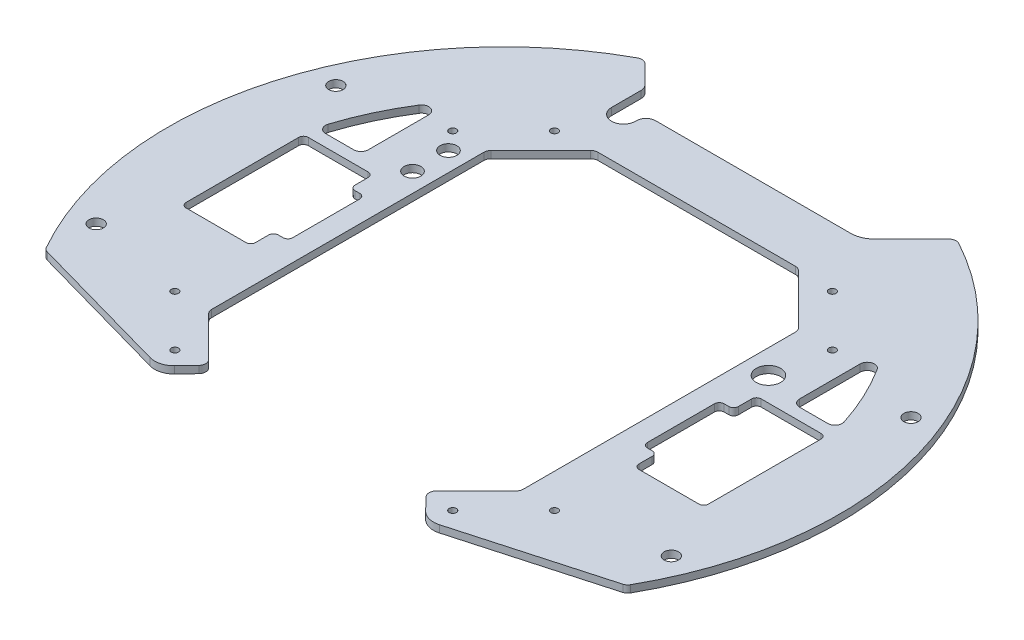
from build123d import *

# Parameters (mm, degrees)
SKETCH1_R            = 140
BOSS_EXTRUDE1_DEPTH  = 3
CUT_EXTRUDE1_REACH   = 5
CUT_EXTRUDE3_REACH   = 5
SKETCH19_R           = 1.5
CUT_EXTRUDE4_REACH   = 5
CUT_EXTRUDE5_REACH   = 5
FILLET1_R            = 20
FILLET2_R            = 10
CUT_EXTRUDE6_REACH   = 5
SKETCH22_W           = 29
SKETCH22_H           = 51
CUT_EXTRUDE15_REACH  = 5
SKETCH31_W           = 6
SKETCH31_H           = 32
FILLET3_R            = 2
CUT_EXTRUDE7_REACH   = 5
SKETCH23_R           = 3
CUT_EXTRUDE8_DEPTH   = 3
FILLET4_R            = 3
FILLET4_OF_MIRROR1_R = 3
CUT_EXTRUDE10_START  = -3
CUT_EXTRUDE10_DEPTH  = 3
CUT_EXTRUDE11_REACH  = 5
SKETCH27_W           = 84.933880008
SKETCH27_H           = 18.347014885
CUT_EXTRUDE12_REACH  = 5
FILLET5_R            = 3
FILLET6_R            = 4
CUT_EXTRUDE13_REACH  = 5
SKETCH29_R           = 5.1
CUT_EXTRUDE14_REACH  = 5
SKETCH30_R           = 3.5


with BuildPart() as part:
    # Sketch1 → Boss-Extrude1 (new body)
    with BuildSketch(Plane(origin=(0, 0, 0), x_dir=(1, 0, 0), z_dir=(0, 1, 0))):
        Circle(SKETCH1_R)
    extrude(amount=BOSS_EXTRUDE1_DEPTH)

    # Sketch17 → Cut-Extrude1 (cut, up to next)
    with BuildSketch(Plane.XZ, mode=Mode.PRIVATE) as cut_extrude1_sk1:
        Polygon((-50, 90), (-121.24355653, 70), (-121.24355653, 140), (121.24355653, 140), (121.24355653, 70), (50, 90), align=None)
    cut_extrude1_tool1 = extrude(cut_extrude1_sk1.sketch, amount=-CUT_EXTRUDE1_REACH, mode=Mode.PRIVATE) & part.part
    add(cut_extrude1_tool1.solids().sort_by_distance((0, 0, 111.669853))[0], mode=Mode.SUBTRACT)

    # Sketch19 → Cut-Extrude3 (cut, up to next)
    with BuildSketch(Plane(origin=(0, 3, 0), x_dir=(1, 0, 0), z_dir=(0, 1, 0)), mode=Mode.PRIVATE) as cut_extrude3_sk1:
        with Locations((-79.195959493, -57.982756057)):
            Circle(SKETCH19_R)
    cut_extrude3_tool1 = extrude(cut_extrude3_sk1.sketch, amount=-CUT_EXTRUDE3_REACH, mode=Mode.PRIVATE) & part.part
    add(cut_extrude3_tool1.solids().sort_by_distance((-79.195959, 3, 57.982756))[0], mode=Mode.SUBTRACT)
    # Sketch19 → Cut-Extrude3 (cut, up to next)
    with BuildSketch(Plane(origin=(0, 3, 0), x_dir=(1, 0, 0), z_dir=(0, 1, 0)), mode=Mode.PRIVATE) as cut_extrude3_sk2:
        with Locations((-79.195959493, 57.982756057)):
            Circle(SKETCH19_R)
    cut_extrude3_tool2 = extrude(cut_extrude3_sk2.sketch, amount=-CUT_EXTRUDE3_REACH, mode=Mode.PRIVATE) & part.part
    add(cut_extrude3_tool2.solids().sort_by_distance((-79.195959, 3, -57.982756))[0], mode=Mode.SUBTRACT)
    # Sketch19 → Cut-Extrude3 (cut, up to next)
    with BuildSketch(Plane(origin=(0, 3, 0), x_dir=(1, 0, 0), z_dir=(0, 1, 0)), mode=Mode.PRIVATE) as cut_extrude3_sk3:
        with Locations((79.195959493, 57.982756057)):
            Circle(SKETCH19_R)
    cut_extrude3_tool3 = extrude(cut_extrude3_sk3.sketch, amount=-CUT_EXTRUDE3_REACH, mode=Mode.PRIVATE) & part.part
    add(cut_extrude3_tool3.solids().sort_by_distance((79.195959, 3, -57.982756))[0], mode=Mode.SUBTRACT)
    # Sketch19 → Cut-Extrude3 (cut, up to next)
    with BuildSketch(Plane(origin=(0, 3, 0), x_dir=(1, 0, 0), z_dir=(0, 1, 0)), mode=Mode.PRIVATE) as cut_extrude3_sk4:
        with Locations((79.195959493, -57.982756057)):
            Circle(SKETCH19_R)
    cut_extrude3_tool4 = extrude(cut_extrude3_sk4.sketch, amount=-CUT_EXTRUDE3_REACH, mode=Mode.PRIVATE) & part.part
    add(cut_extrude3_tool4.solids().sort_by_distance((79.195959, 3, 57.982756))[0], mode=Mode.SUBTRACT)
    # Sketch19 → Cut-Extrude3 (cut, up to next)
    with BuildSketch(Plane(origin=(0, 3, 0), x_dir=(1, 0, 0), z_dir=(0, 1, 0)), mode=Mode.PRIVATE) as cut_extrude3_sk5:
        with Locations((-57.982756057, -79.195959493)):
            Circle(SKETCH19_R)
    cut_extrude3_tool5 = extrude(cut_extrude3_sk5.sketch, amount=-CUT_EXTRUDE3_REACH, mode=Mode.PRIVATE) & part.part
    add(cut_extrude3_tool5.solids().sort_by_distance((-57.982756, 3, 79.195959))[0], mode=Mode.SUBTRACT)
    # Sketch19 → Cut-Extrude3 (cut, up to next)
    with BuildSketch(Plane(origin=(0, 3, 0), x_dir=(1, 0, 0), z_dir=(0, 1, 0)), mode=Mode.PRIVATE) as cut_extrude3_sk6:
        with Locations((57.982756057, 79.195959493)):
            Circle(SKETCH19_R)
    cut_extrude3_tool6 = extrude(cut_extrude3_sk6.sketch, amount=-CUT_EXTRUDE3_REACH, mode=Mode.PRIVATE) & part.part
    add(cut_extrude3_tool6.solids().sort_by_distance((57.982756, 3, -79.195959))[0], mode=Mode.SUBTRACT)
    # Sketch19 → Cut-Extrude3 (cut, up to next)
    with BuildSketch(Plane(origin=(0, 3, 0), x_dir=(1, 0, 0), z_dir=(0, 1, 0)), mode=Mode.PRIVATE) as cut_extrude3_sk7:
        with Locations((-57.982756057, 79.195959493)):
            Circle(SKETCH19_R)
    cut_extrude3_tool7 = extrude(cut_extrude3_sk7.sketch, amount=-CUT_EXTRUDE3_REACH, mode=Mode.PRIVATE) & part.part
    add(cut_extrude3_tool7.solids().sort_by_distance((-57.982756, 3, -79.195959))[0], mode=Mode.SUBTRACT)
    # Sketch19 → Cut-Extrude3 (cut, up to next)
    with BuildSketch(Plane(origin=(0, 3, 0), x_dir=(1, 0, 0), z_dir=(0, 1, 0)), mode=Mode.PRIVATE) as cut_extrude3_sk8:
        with Locations((57.982756057, -79.195959493)):
            Circle(SKETCH19_R)
    cut_extrude3_tool8 = extrude(cut_extrude3_sk8.sketch, amount=-CUT_EXTRUDE3_REACH, mode=Mode.PRIVATE) & part.part
    add(cut_extrude3_tool8.solids().sort_by_distance((57.982756, 3, 79.195959))[0], mode=Mode.SUBTRACT)

    # Sketch20 → Cut-Extrude4 (cut, up to next)
    with BuildSketch(Plane(origin=(0, 3, 0), x_dir=(1, 0, 0), z_dir=(0, 1, 0)), mode=Mode.PRIVATE) as cut_extrude4_sk1:
        Polygon((-491.163597408, 550.159565085), (-65, 123.995967676), (-45, 103.995967676), (45, 103.995967676), (65, 123.995967676), (491.163597408, 550.159565085), (491.163597408, 1755.532243574), (-491.163597408, 1755.532243574), align=None)
    cut_extrude4_tool1 = extrude(cut_extrude4_sk1.sketch, amount=-CUT_EXTRUDE4_REACH, mode=Mode.PRIVATE) & part.part
    add(cut_extrude4_tool1.solids().sort_by_distance((0, 3, -1024.45638))[0], mode=Mode.SUBTRACT)

    # Sketch21 → Cut-Extrude5 (cut, up to next)
    with BuildSketch(Plane(origin=(0, 3, 0), x_dir=(1, 0, 0), z_dir=(0, 1, 0)), mode=Mode.PRIVATE) as cut_extrude5_sk1:
        with BuildLine():
            Line((-42.466940004, 80.569639922), (0, 60))
            Line((0, 60), (42.466940004, 80.569639922))
            Line((42.466940004, 80.569639922), (59.955847787, 63.08073214))
            Line((59.955847787, 63.08073214), (40, 15))
            Line((40, 15), (61.390574802, -61.646005125))
            Line((61.390574802, -61.646005125), (45.420177914, -77.616402013))
            Line((45.420177914, -77.616402013), (52.384945698, -84.917940623))
            ThreePointArc((52.384945698, -84.917940623), (56.057931023, -87.111303002), (60.335955528, -87.098416746))
            Line((60.335955528, -87.098416746), (50, -90))
            Line((50, -90), (-50, -90))
            Line((-50, -90), (-60.335955528, -87.098416746))
            ThreePointArc((-60.335955528, -87.098416746), (-56.057931023, -87.111303002), (-52.384945698, -84.917940623))
            Line((-52.384945698, -84.917940623), (-45.420177914, -77.616402013))
            Line((-45.420177914, -77.616402013), (-61.390574802, -61.646005125))
            Line((-61.390574802, -61.646005125), (-40, 15))
            Line((-40, 15), (-59.955847787, 63.08073214))
            Line((-59.955847787, 63.08073214), (-42.466940004, 80.569639922))
        make_face()
    cut_extrude5_tool1 = extrude(cut_extrude5_sk1.sketch, amount=-CUT_EXTRUDE5_REACH, mode=Mode.PRIVATE) & part.part
    add(cut_extrude5_tool1.solids().sort_by_distance((0, 3, 10.206035))[0], mode=Mode.SUBTRACT)

    # Fillet1
    fillet1_edges = [part.edges().sort_by_distance(p)[0] for p in [
        (-40, 1.5, -15),
        (0, 1.5, -60),
        (40, 1.5, -15),
    ]]
    fillet(fillet1_edges, radius=FILLET1_R)

    # Fillet2
    fillet2_edges = [part.edges().sort_by_distance(p)[0] for p in [
        (45, 1.5, -103.995967676),
        (-45, 1.5, -103.995967676),
    ]]
    fillet(fillet2_edges, radius=FILLET2_R)

    # Sketch22 → Cut-Extrude6 (cut, up to next)
    with BuildSketch(Plane(origin=(0, 3, 0), x_dir=(1, 0, 0), z_dir=(0, 1, 0)), mode=Mode.PRIVATE) as cut_extrude6_sk1:
        with Locations((94.5, 0)):
            Rectangle(SKETCH22_W, SKETCH22_H)
    cut_extrude6_tool1 = extrude(cut_extrude6_sk1.sketch, amount=-CUT_EXTRUDE6_REACH, mode=Mode.PRIVATE) & part.part
    add(cut_extrude6_tool1.solids().sort_by_distance((94.5, 3, 0))[0], mode=Mode.SUBTRACT)
    # Sketch22 → Cut-Extrude6 (cut, up to next)
    with BuildSketch(Plane(origin=(0, 3, 0), x_dir=(1, 0, 0), z_dir=(0, 1, 0)), mode=Mode.PRIVATE) as cut_extrude6_sk2:
        with Locations((-94.5, 0)):
            Rectangle(SKETCH22_W, SKETCH22_H)
    cut_extrude6_tool2 = extrude(cut_extrude6_sk2.sketch, amount=-CUT_EXTRUDE6_REACH, mode=Mode.PRIVATE) & part.part
    add(cut_extrude6_tool2.solids().sort_by_distance((-94.5, 3, 0))[0], mode=Mode.SUBTRACT)

    # Sketch31 → Cut-Extrude15 (cut, up to next)
    with BuildSketch(Plane(origin=(0, 3, 0), x_dir=(1, 0, 0), z_dir=(0, 1, 0)), mode=Mode.PRIVATE) as cut_extrude15_sk1:
        with Locations((-77, 0)):
            Rectangle(SKETCH31_W, SKETCH31_H)
    cut_extrude15_tool1 = extrude(cut_extrude15_sk1.sketch, amount=-CUT_EXTRUDE15_REACH, mode=Mode.PRIVATE) & part.part
    add(cut_extrude15_tool1.solids().sort_by_distance((-77, 3, 0))[0], mode=Mode.SUBTRACT)
    # Sketch31 → Cut-Extrude15 (cut, up to next)
    with BuildSketch(Plane(origin=(0, 3, 0), x_dir=(1, 0, 0), z_dir=(0, 1, 0)), mode=Mode.PRIVATE) as cut_extrude15_sk2:
        with Locations((77, 0)):
            Rectangle(SKETCH31_W, SKETCH31_H)
    cut_extrude15_tool2 = extrude(cut_extrude15_sk2.sketch, amount=-CUT_EXTRUDE15_REACH, mode=Mode.PRIVATE) & part.part
    add(cut_extrude15_tool2.solids().sort_by_distance((77, 3, 0))[0], mode=Mode.SUBTRACT)

    # Fillet3
    fillet3_edges = [part.edges().sort_by_distance(p)[0] for p in [
        (80, 1.5, 25.5),
        (80, 1.5, -25.5),
        (109, 1.5, -25.5),
        (109, 1.5, 25.5),
        (-109, 1.5, 25.5),
        (-109, 1.5, -25.5),
        (-80, 1.5, -25.5),
        (-80, 1.5, 25.5),
        (-80, 1.5, 16),
        (-80, 1.5, -16),
        (-74, 1.5, -16),
        (-74, 1.5, 16),
        (80, 1.5, -16),
        (80, 1.5, 16),
        (74, 1.5, 16),
        (74, 1.5, -16),
    ]]
    fillet(fillet3_edges, radius=FILLET3_R)

    # Sketch23 → Cut-Extrude7 (cut, up to next)
    with BuildSketch(Plane(origin=(0, 3, 0), x_dir=(1, 0, 0), z_dir=(0, 1, 0)), mode=Mode.PRIVATE) as cut_extrude7_sk1:
        with Locations((-120, 50)):
            Circle(SKETCH23_R)
    cut_extrude7_tool1 = extrude(cut_extrude7_sk1.sketch, amount=-CUT_EXTRUDE7_REACH, mode=Mode.PRIVATE) & part.part
    add(cut_extrude7_tool1.solids().sort_by_distance((-120, 3, -50))[0], mode=Mode.SUBTRACT)
    # Sketch23 → Cut-Extrude7 (cut, up to next)
    with BuildSketch(Plane(origin=(0, 3, 0), x_dir=(1, 0, 0), z_dir=(0, 1, 0)), mode=Mode.PRIVATE) as cut_extrude7_sk2:
        with Locations((-120, -50)):
            Circle(SKETCH23_R)
    cut_extrude7_tool2 = extrude(cut_extrude7_sk2.sketch, amount=-CUT_EXTRUDE7_REACH, mode=Mode.PRIVATE) & part.part
    add(cut_extrude7_tool2.solids().sort_by_distance((-120, 3, 50))[0], mode=Mode.SUBTRACT)
    # Sketch23 → Cut-Extrude7 (cut, up to next)
    with BuildSketch(Plane(origin=(0, 3, 0), x_dir=(1, 0, 0), z_dir=(0, 1, 0)), mode=Mode.PRIVATE) as cut_extrude7_sk3:
        with Locations((120, -50)):
            Circle(SKETCH23_R)
    cut_extrude7_tool3 = extrude(cut_extrude7_sk3.sketch, amount=-CUT_EXTRUDE7_REACH, mode=Mode.PRIVATE) & part.part
    add(cut_extrude7_tool3.solids().sort_by_distance((120, 3, 50))[0], mode=Mode.SUBTRACT)
    # Sketch23 → Cut-Extrude7 (cut, up to next)
    with BuildSketch(Plane(origin=(0, 3, 0), x_dir=(1, 0, 0), z_dir=(0, 1, 0)), mode=Mode.PRIVATE) as cut_extrude7_sk4:
        with Locations((120, 50)):
            Circle(SKETCH23_R)
    cut_extrude7_tool4 = extrude(cut_extrude7_sk4.sketch, amount=-CUT_EXTRUDE7_REACH, mode=Mode.PRIVATE) & part.part
    add(cut_extrude7_tool4.solids().sort_by_distance((120, 3, -50))[0], mode=Mode.SUBTRACT)

    # Sketch24 → Cut-Extrude8 (cut)
    with BuildSketch(Plane(origin=(0, 3, 0), x_dir=(1, 0, 0), z_dir=(0, 1, 0))):
        with BuildLine():
            Line((-90, 68.330081223), (-90, 30.5))
            Line((-90, 30.5), (-108.806020054, 30.5))
            ThreePointArc((-108.806020054, 30.5), (-101.186645185, 50.301718025), (-90, 68.330081223))
        make_face()
    cut_extrude8 = extrude(amount=-CUT_EXTRUDE8_DEPTH, mode=Mode.SUBTRACT)

    # Fillet4
    fillet4_edges = [part.edges().sort_by_distance(p)[0] for p in [
        (-108.806020054, 1.5, -30.5),
        (-90, 1.5, -68.330081223),
        (-90, 1.5, -30.5),
    ]]
    fillet(fillet4_edges, radius=FILLET4_R)

    # Mirror1: Cut-Extrude8 across plane
    add(cut_extrude8.mirror(Plane(origin=(0, 0, 0), x_dir=(0, 0, 1), z_dir=(1, 0, 0))), mode=Mode.SUBTRACT)

    # Fillet4 of Mirror1
    fillet4_of_mirror1_edges = [part.edges().sort_by_distance(p)[0] for p in [
        (108.806020054, 1.5, -30.5),
        (90, 1.5, -68.330081223),
        (90, 1.5, -30.5),
    ]]
    fillet(fillet4_of_mirror1_edges, radius=FILLET4_OF_MIRROR1_R)

    # Sketch26 → Cut-Extrude10 (cut)
    with BuildSketch(Plane(origin=(0, 3, 0), x_dir=(1, 0, 0), z_dir=(0, 1, 0)).offset(CUT_EXTRUDE10_START)):
        Polygon((-59.955847787, 63.08073214), (-65, 58.036579926), (-65, -58.036579926), (-61.390574802, -61.646005125), (61.390574802, -61.646005125), (65, -58.036579926), (65, 58.036579926), (59.955847787, 63.08073214), align=None)
    extrude(amount=CUT_EXTRUDE10_DEPTH, mode=Mode.SUBTRACT)

    # Sketch27 → Cut-Extrude11 (cut, up to next)
    with BuildSketch(Plane(origin=(0, 3, 0), x_dir=(1, 0, 0), z_dir=(0, 1, 0)), mode=Mode.PRIVATE) as cut_extrude11_sk1:
        with Locations((0, 71.39613248)):
            Rectangle(SKETCH27_W, SKETCH27_H)
    cut_extrude11_tool1 = extrude(cut_extrude11_sk1.sketch, amount=-CUT_EXTRUDE11_REACH, mode=Mode.PRIVATE) & part.part
    add(cut_extrude11_tool1.solids().sort_by_distance((0, 3, -71.396132))[0], mode=Mode.SUBTRACT)

    # Sketch28 → Cut-Extrude12 (cut, up to next)
    with BuildSketch(Plane(origin=(0, 3, 0), x_dir=(1, 0, 0), z_dir=(0, 1, 0)), mode=Mode.PRIVATE) as cut_extrude12_sk1:
        with BuildLine():
            Line((-54.55, 99.6), (-54.55, 119.6))
            ThreePointArc((-54.55, 119.6), (-49.55, 124.6), (-44.55, 119.6))
            Line((-44.55, 119.6), (-44.55, 99.6))
            ThreePointArc((-44.55, 99.6), (-49.55, 94.6), (-54.55, 99.6))
        make_face()
    cut_extrude12_tool1 = extrude(cut_extrude12_sk1.sketch, amount=-CUT_EXTRUDE12_REACH, mode=Mode.PRIVATE) & part.part
    add(cut_extrude12_tool1.solids().sort_by_distance((-49.55, 3, -109.6))[0], mode=Mode.SUBTRACT)

    # Fillet5
    fillet5_edges = [part.edges().sort_by_distance(p)[0] for p in [
        (121.24355653, 1.5, 70),
        (-121.24355653, 1.5, 70),
        (-65, 1.5, -58.036579926),
        (-65, 1.5, 58.036579926),
        (65, 1.5, -58.036579926),
        (65, 1.5, 58.036579926),
        (65, 1.5, -123.995967676),
        (-65, 1.5, -123.995967676),
        (-45.420177914, 1.5, 77.616402013),
        (-42.466940004, 1.5, -80.569639922),
        (42.466940004, 1.5, -80.569639922),
        (45.420177914, 1.5, 77.616402013),
    ]]
    fillet(fillet5_edges, radius=FILLET5_R)

    # Fillet6
    fillet6_edges = [part.edges().sort_by_distance(p)[0] for p in [
        (-44.55, 1.5, -104.702521893),
        (-54.55, 1.5, -113.545967676),
    ]]
    fillet(fillet6_edges, radius=FILLET6_R)

    # Sketch29 → Cut-Extrude13 (cut, up to next)
    with BuildSketch(Plane(origin=(0, 3, 0), x_dir=(1, 0, 0), z_dir=(0, 1, 0)), mode=Mode.PRIVATE) as cut_extrude13_sk1:
        with Locations((75, 35.5)):
            Circle(SKETCH29_R)
    cut_extrude13_tool1 = extrude(cut_extrude13_sk1.sketch, amount=-CUT_EXTRUDE13_REACH, mode=Mode.PRIVATE) & part.part
    add(cut_extrude13_tool1.solids().sort_by_distance((75, 3, -35.5))[0], mode=Mode.SUBTRACT)

    # Sketch30 → Cut-Extrude14 (cut, up to next)
    with BuildSketch(Plane(origin=(0, 3, 0), x_dir=(1, 0, 0), z_dir=(0, 1, 0)), mode=Mode.PRIVATE) as cut_extrude14_sk1:
        with Locations((-73, 50)):
            Circle(SKETCH30_R)
    cut_extrude14_tool1 = extrude(cut_extrude14_sk1.sketch, amount=-CUT_EXTRUDE14_REACH, mode=Mode.PRIVATE) & part.part
    add(cut_extrude14_tool1.solids().sort_by_distance((-73, 3, -50))[0], mode=Mode.SUBTRACT)
    # Sketch30 → Cut-Extrude14 (cut, up to next)
    with BuildSketch(Plane(origin=(0, 3, 0), x_dir=(1, 0, 0), z_dir=(0, 1, 0)), mode=Mode.PRIVATE) as cut_extrude14_sk2:
        with Locations((-73, 35)):
            Circle(SKETCH30_R)
    cut_extrude14_tool2 = extrude(cut_extrude14_sk2.sketch, amount=-CUT_EXTRUDE14_REACH, mode=Mode.PRIVATE) & part.part
    add(cut_extrude14_tool2.solids().sort_by_distance((-73, 3, -35))[0], mode=Mode.SUBTRACT)


solid = part.part
